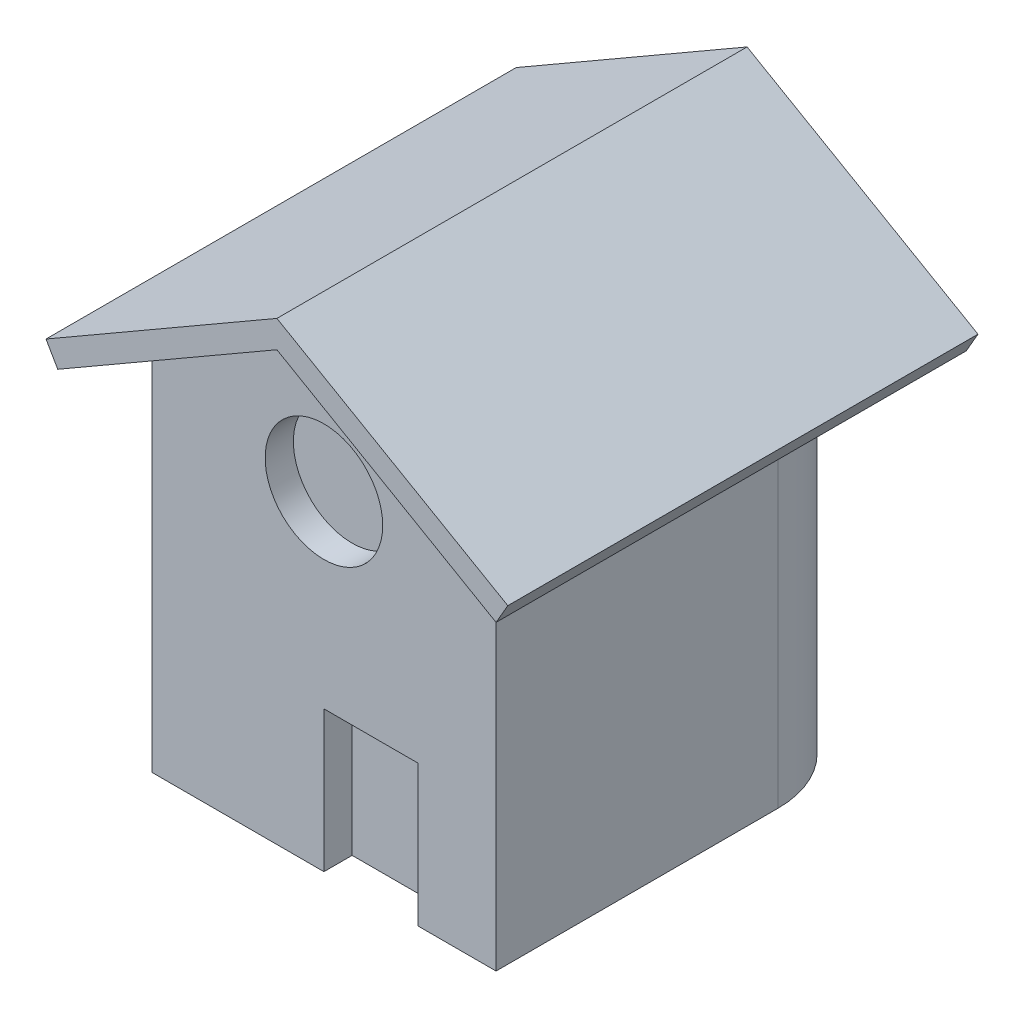
from build123d import *

# Parameters (mm, degrees)
BOSS_EXTRUDE1_DEPTH = 20
SKETCH2_R           = 6.25
SKETCH2_W           = 10
SKETCH2_H           = 15
CUT_EXTRUDE1_DEPTH  = 3
FILLET2_R           = 10
BOSS_EXTRUDE2_DEPTH = 25


with BuildPart() as part:
    # Sketch1 → Boss-Extrude1 (new body, symmetric)
    with BuildSketch(Plane.XY):
        Polygon((-18.305, 0), (18.305, 0), (18.305, 40), (0, 50.568396678), (-18.305, 40), align=None)
    extrude(amount=BOSS_EXTRUDE1_DEPTH, both=True)

    # Sketch2 → Cut-Extrude1 (cut)
    with BuildSketch(Plane.XY.offset(20)):
        with Locations((0, 35)):
            Circle(SKETCH2_R)
        with Locations((5, 7.5)):
            Rectangle(SKETCH2_W, SKETCH2_H)
    extrude(amount=-CUT_EXTRUDE1_DEPTH, mode=Mode.SUBTRACT)

    # Fillet2
    fillet2_edges = [part.edges().sort_by_distance(p)[0] for p in [
        (18.305, 20, -20),
        (-18.305, 20, -20),
    ]]
    fillet(fillet2_edges, radius=FILLET2_R)

    # Sketch3 → Boss-Extrude2 (add, symmetric)
    with BuildSketch(Plane.XY):
        Polygon((0, 50.568396678), (23.305, 37.113248654), (24.555, 39.278312164), (0, 53.455148023), (-24.555, 39.278312164), (-23.305, 37.113248654), align=None)
    extrude(amount=BOSS_EXTRUDE2_DEPTH, both=True)


solid = part.part
